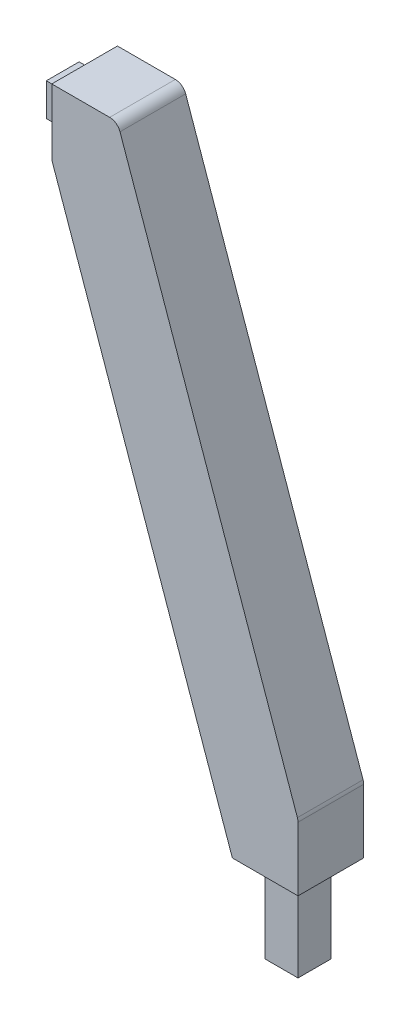
from build123d import *

# Parameters (mm, degrees)
BOSS_EXTRUDE1_DEPTH = 30
SKETCH2_W           = 14.98
SKETCH2_H           = 14.98
BOSS_EXTRUDE2_DEPTH = 10
SKETCH3_W           = 14.98
SKETCH3_H           = 14.98
BOSS_EXTRUDE3_DEPTH = 40
FILLET1_R           = 5


with BuildPart() as part:
    # Sketch1 → Boss-Extrude1 (new body)
    with BuildSketch(Plane.XY):
        Polygon((0, 0), (-30, 0), (-112.5, 235), (-112.5, 265), (-82.5, 265), (0, 30), align=None)
    extrude(amount=BOSS_EXTRUDE1_DEPTH)

    # Sketch2 → Boss-Extrude2 (add)
    with BuildSketch(Plane.ZY.offset(112.5)):
        with Locations((15, 250)):
            Rectangle(SKETCH2_W, SKETCH2_H)
    extrude(amount=BOSS_EXTRUDE2_DEPTH)

    # Sketch3 → Boss-Extrude3 (add)
    with BuildSketch(Plane.XZ):
        with Locations((-15, 15)):
            Rectangle(SKETCH3_W, SKETCH3_H)
    extrude(amount=BOSS_EXTRUDE3_DEPTH)

    # Fillet1
    fillet1_edges = [part.edges().sort_by_distance(p)[0] for p in [
        (-82.5, 265, 15),
        (0, 30, 15),
    ]]
    fillet(fillet1_edges, radius=FILLET1_R)


solid = part.part
